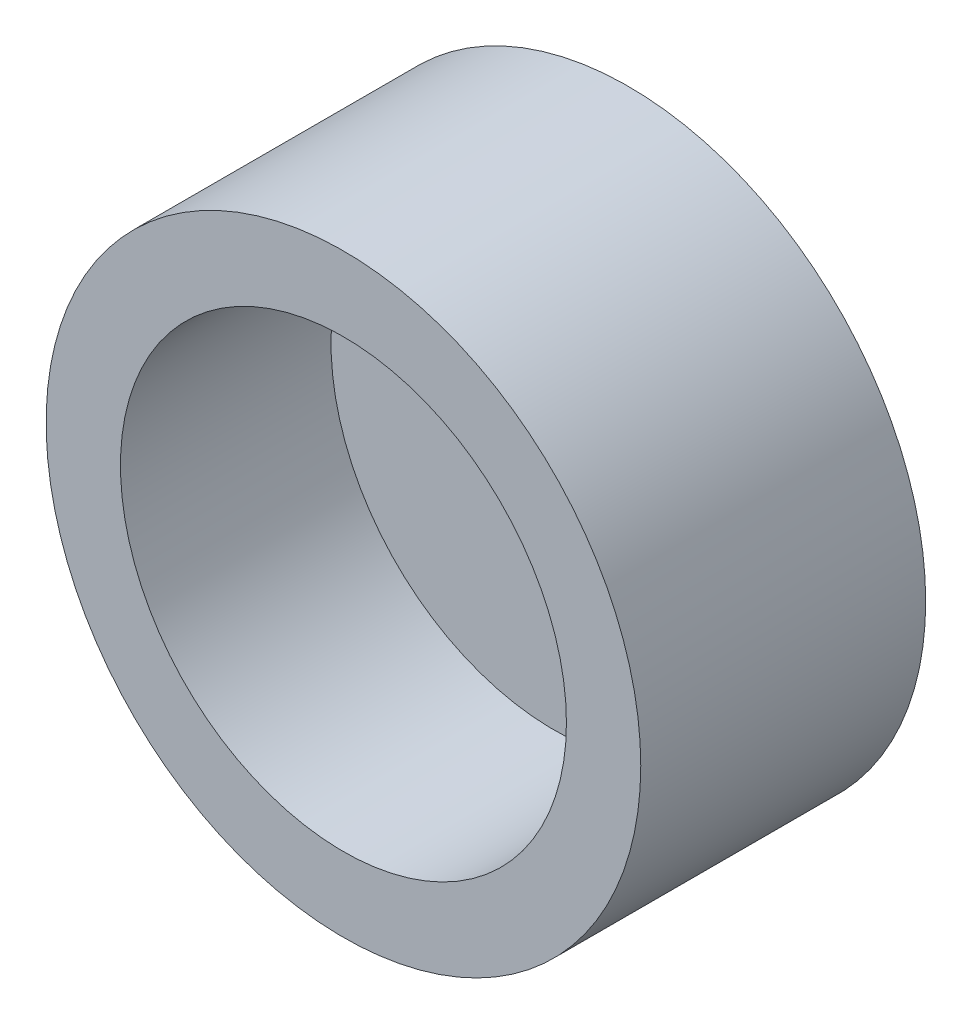
from build123d import *

# Parameters (mm, degrees)
SKETCH1_R           = 12
SKETCH1_R_2         = 9
BOSS_EXTRUDE1_DEPTH = 8.5
BOSS_EXTRUDE2_START = -3
SKETCH1_2_R         = 12
BOSS_EXTRUDE2_DEPTH = 3
SKETCH2_R           = 5
CUT_EXTRUDE1_DEPTH  = 2


with BuildPart() as part:
    # Sketch1 → Boss-Extrude1 (new body)
    with BuildSketch(Plane.XY):
        Circle(SKETCH1_R)
        Circle(SKETCH1_R_2, mode=Mode.SUBTRACT)
    extrude(amount=BOSS_EXTRUDE1_DEPTH)

    # Sketch1_2 → Boss-Extrude2 (add)
    with BuildSketch(Plane.XY.offset(BOSS_EXTRUDE2_START)):
        Circle(SKETCH1_2_R)
    extrude(amount=BOSS_EXTRUDE2_DEPTH)

    # Sketch2 → Cut-Extrude1 (cut)
    with BuildSketch(Plane(origin=(0, 0, -3), x_dir=(-1, 0, 0), z_dir=(0, 0, -1))):
        Circle(SKETCH2_R)
    extrude(amount=-CUT_EXTRUDE1_DEPTH, mode=Mode.SUBTRACT)


solid = part.part
